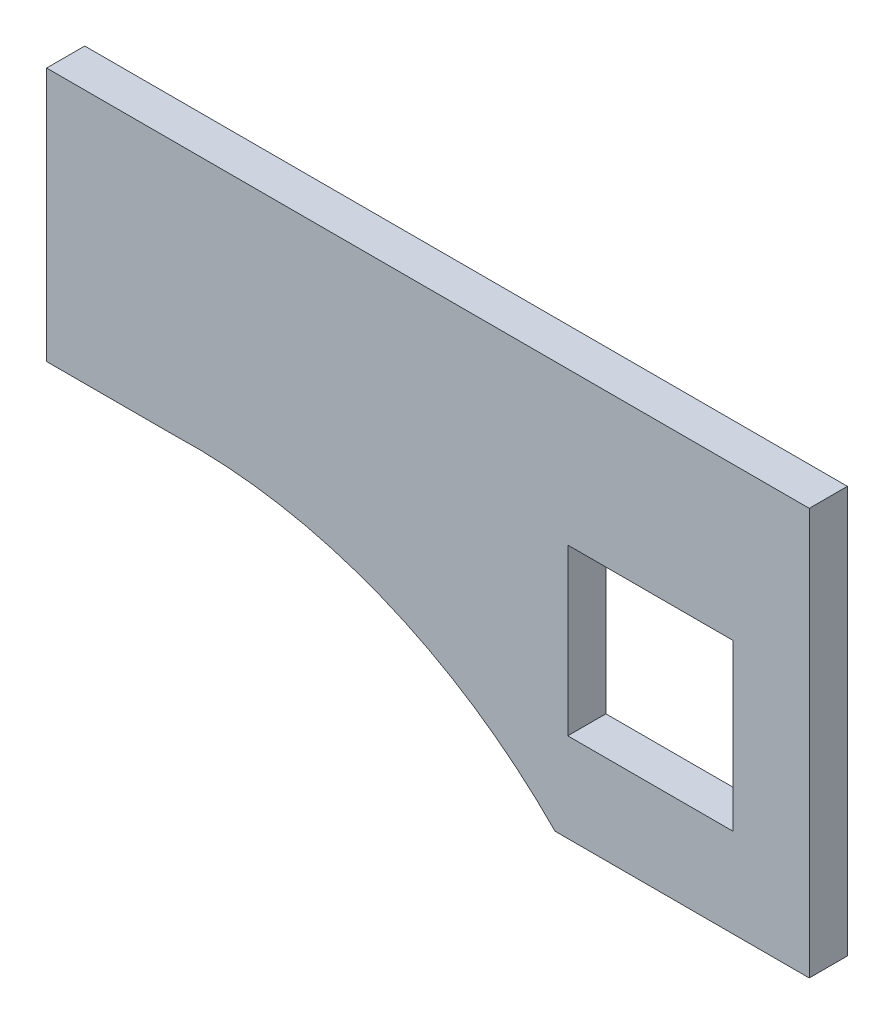
from build123d import *

# Parameters (mm, degrees)
BOSS_EXTRUDE1_DEPTH = 1.5
SKETCH3_W           = 6.5
SKETCH3_H           = 6.5
CUT_EXTRUDE1_DEPTH  = 2


with BuildPart() as part:
    # Sketch2 → Boss-Extrude1 (new body)
    with BuildSketch(Plane.XY):
        with BuildLine():
            Line((-7.517156851, 8.129598801), (22.482843149, 8.129598801))
            Line((22.482843149, 8.129598801), (22.482843149, -7.870401199))
            Line((22.482843149, -7.870401199), (12.482843149, -7.870401199))
            ThreePointArc((12.482843149, -7.870401199), (5.615628068, -3.288438903), (-2.517156851, -1.870401199))
            Line((-2.517156851, -1.870401199), (-7.517156851, -1.870401199))
            Line((-7.517156851, -1.870401199), (-7.517156851, 8.129598801))
        make_face()
    extrude(amount=BOSS_EXTRUDE1_DEPTH)

    # Sketch3 → Cut-Extrude1 (cut)
    with BuildSketch(Plane.XY.offset(1.5)):
        with Locations((16.232843149, -1.120401199)):
            Rectangle(SKETCH3_W, SKETCH3_H)
    extrude(amount=-CUT_EXTRUDE1_DEPTH, mode=Mode.SUBTRACT)


solid = part.part
